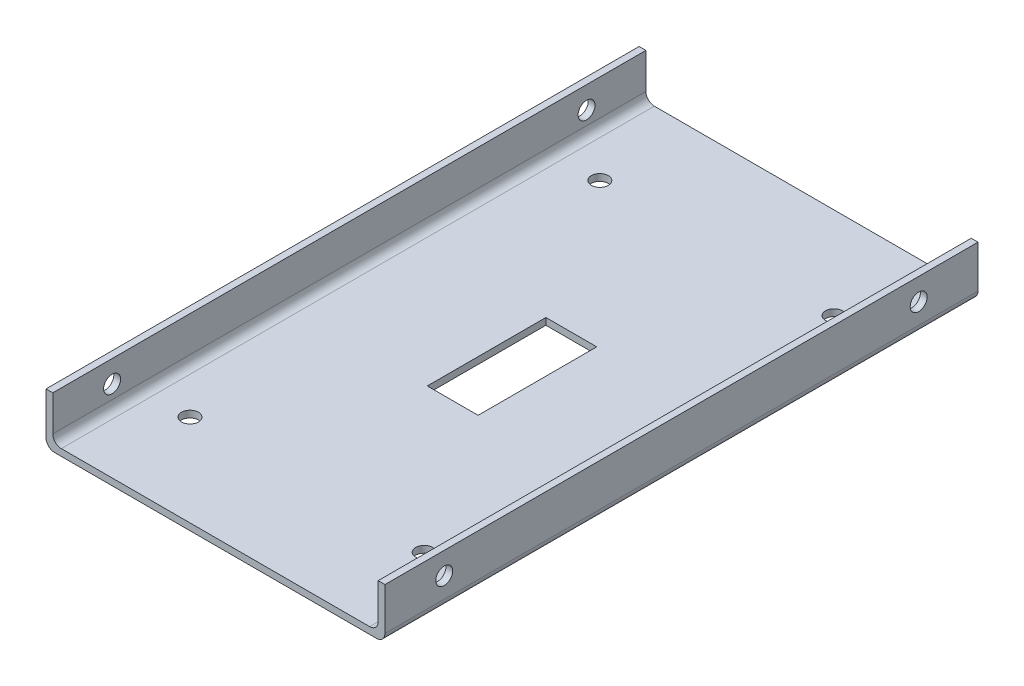
from build123d import *

# Parameters (mm, degrees)
BOSS_EXTRUDE1_DEPTH = 350
FILLET1_R           = 5
SKETCH2_R           = 5
CUT_EXTRUDE1_DEPTH  = 300
SKETCH3_R           = 5
SKETCH3_W           = 30
SKETCH3_H           = 70
CUT_EXTRUDE6_DEPTH  = 10


with BuildPart() as part:
    # Sketch1 → Boss-Extrude1 (new body)
    with BuildSketch(Plane.XY):
        Polygon((0, 0), (200, 0), (200, 30), (196, 30), (196, 4), (4, 4), (4, 30), (0, 30), align=None)
    extrude(amount=BOSS_EXTRUDE1_DEPTH)

    # Fillet1
    fillet1_edges = [part.edges().sort_by_distance(p)[0] for p in [
        (4, 4, 175),
        (196, 4, 175),
        (200, 0, 175),
        (0, 0, 175),
    ]]
    fillet(fillet1_edges, radius=FILLET1_R)

    # Sketch2 → Cut-Extrude1 (cut)
    with BuildSketch(Plane(origin=(200, 0, 0), x_dir=(0, 0, -1), z_dir=(1, 0, 0))):
        with Locations((-315, 17)):
            Circle(SKETCH2_R)
        with Locations((-35, 17)):
            Circle(SKETCH2_R)
    extrude(amount=-CUT_EXTRUDE1_DEPTH, mode=Mode.SUBTRACT)

    # Sketch3 → Cut-Extrude6 (cut)
    with BuildSketch(Plane(origin=(0, 0, 0), x_dir=(1, 0, 0), z_dir=(0, 1, 0))):
        with Locations((30.894933586, -54.066133776)):
            Circle(SKETCH3_R)
        with Locations((169.105066414, -54.066133776)):
            Circle(SKETCH3_R)
        with Locations((169.105066414, -295.933866224)):
            Circle(SKETCH3_R)
        with Locations((30.894933586, -295.933866224)):
            Circle(SKETCH3_R)
        with Locations((100, -175)):
            Rectangle(SKETCH3_W, SKETCH3_H)
    extrude(amount=CUT_EXTRUDE6_DEPTH, mode=Mode.SUBTRACT)


solid = part.part
